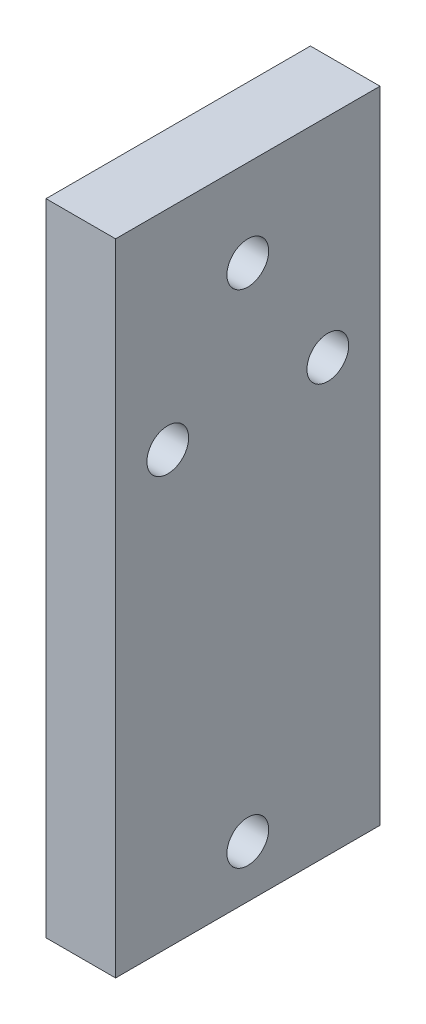
from build123d import *

# Parameters (mm, degrees)
SKETCH1_W           = 38
SKETCH1_H           = 92
BOSS_EXTRUDE1_DEPTH = 10
SKETCH4_W           = 7
SKETCH4_H           = 7
CUT_EXTRUDE3_DEPTH  = 3
SKETCH7_R           = 3
CUT_EXTRUDE4_DEPTH  = 8
SKETCH8_R           = 3
CUT_EXTRUDE5_DEPTH  = 11
SKETCH9_R           = 3
CUT_EXTRUDE6_DEPTH  = 11


with BuildPart() as part:
    # Sketch1 → Boss-Extrude1 (new body)
    with BuildSketch(Plane(origin=(0, 0, 0), x_dir=(0, 0, -1), z_dir=(1, 0, 0))):
        with Locations((1.34375, -37.65625)):
            Rectangle(SKETCH1_W, SKETCH1_H)
    extrude(amount=BOSS_EXTRUDE1_DEPTH)

    # Sketch4 → Cut-Extrude3 (cut)
    with BuildSketch(Plane.ZY):
        with Locations((-1.34375, -4.15625)):
            Rectangle(SKETCH4_W, SKETCH4_H)
    extrude(amount=-CUT_EXTRUDE3_DEPTH, mode=Mode.SUBTRACT)

    # Sketch7 → Cut-Extrude4 (cut, through all)
    with BuildSketch(Plane.ZY.offset(-3)):
        with Locations((-1.34375, -4.15625)):
            Circle(SKETCH7_R)
    extrude(amount=-CUT_EXTRUDE4_DEPTH, mode=Mode.SUBTRACT)

    # Sketch8 → Cut-Extrude5 (cut, through all)
    with BuildSketch(Plane.ZY):
        with Locations((-1.34375, -76.15625)):
            Circle(SKETCH8_R)
    extrude(amount=-CUT_EXTRUDE5_DEPTH, mode=Mode.SUBTRACT)

    # Sketch9 → Cut-Extrude6 (cut, through all)
    with BuildSketch(Plane.ZY):
        with Locations((10.15625, -21.65625)):
            Circle(SKETCH9_R)
        with Locations((-12.84375, -21.65625)):
            Circle(SKETCH9_R)
    extrude(amount=-CUT_EXTRUDE6_DEPTH, mode=Mode.SUBTRACT)


solid = part.part
